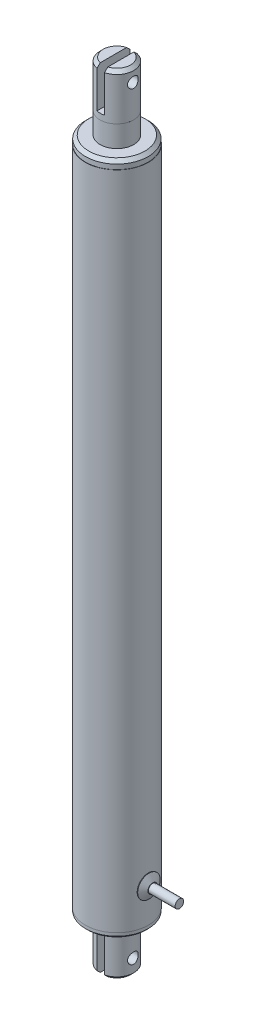
from build123d import *

# Parameters (mm, degrees)
SKETCH1_R           = 14.986
BOSS_EXTRUDE1_DEPTH = 313.944
SKETCH2_R           = 14.859
BOSS_EXTRUDE2_DEPTH = 2.54
CHAMFER1_SIZE       = 1.016
SKETCH3_R           = 8.001
BOSS_EXTRUDE3_DEPTH = 22.098
CHAMFER2_SIZE       = 1.524
SKETCH4_R           = 2.54
CUT_EXTRUDE1_DEPTH  = 21.59
SKETCH5_W           = 3.556
SKETCH5_H           = 22.881169146
CUT_EXTRUDE2_DEPTH  = 21.59
SKETCH6_R           = 5.334
BOSS_EXTRUDE4_DEPTH = 2.032
CHAMFER3_SIZE       = 1.778
CHAMFER3_SIZE2      = 3.079586336
SKETCH7_R           = 2.032
BOSS_EXTRUDE5_DEPTH = 12.7
SKETCH8_R           = 14.859
BOSS_EXTRUDE6_DEPTH = 3.81
CHAMFER4_SIZE       = 1.524
SKETCH9_R           = 8.001
BOSS_EXTRUDE7_DEPTH = 10.16
SKETCH10_R          = 8.001
BOSS_EXTRUDE8_DEPTH = 21.844
CHAMFER5_SIZE       = 1.524
SKETCH11_R          = 2.54
CUT_EXTRUDE3_DEPTH  = 21.844
SKETCH12_W          = 3.556
SKETCH12_H          = 19.05
CUT_EXTRUDE4_DEPTH  = 21.844


with BuildPart() as part:
    # Sketch1 → Boss-Extrude1 (new body)
    with BuildSketch(Plane(origin=(0, 0, 0), x_dir=(1, 0, 0), z_dir=(0, 1, 0))):
        with Locations(Location((0, 0, 0), (0, 0, 270))):  # turned: the seam where the file's is
            Circle(SKETCH1_R)
    extrude(amount=BOSS_EXTRUDE1_DEPTH)

    # Sketch2 → Boss-Extrude2 (add)
    with BuildSketch(Plane.XZ):
        with Locations(Location((0, 0, 0), (0, 0, 90))):  # turned: the seam where the file's is
            Circle(SKETCH2_R)
    extrude(amount=BOSS_EXTRUDE2_DEPTH)

    # Chamfer1
    chamfer1_edges = [part.edges().sort_by_distance(p)[0] for p in [
        (0, -2.54, -14.859),
    ]]
    chamfer(chamfer1_edges, length=CHAMFER1_SIZE)

    # Sketch3 → Boss-Extrude3 (add)
    with BuildSketch(Plane.XZ.offset(2.54)):
        with Locations(Location((0, 0, 0), (0, 0, 270))):  # turned: the seam where the file's is
            Circle(SKETCH3_R)
    extrude(amount=BOSS_EXTRUDE3_DEPTH)

    # Chamfer2
    chamfer2_edges = [part.edges().sort_by_distance(p)[0] for p in [
        (0, -24.638, 8.001),
    ]]
    chamfer(chamfer2_edges, length=CHAMFER2_SIZE)

    # Sketch4 → Cut-Extrude1 (cut)
    with BuildSketch(Plane.ZY.offset(8.001)):
        with Locations((0, -17.018)):
            Circle(SKETCH4_R)
    extrude(amount=-CUT_EXTRUDE1_DEPTH, mode=Mode.SUBTRACT)

    # Sketch5 → Cut-Extrude2 (cut)
    with BuildSketch(Plane(origin=(0, 0, -8.001), x_dir=(-1, 0, 0), z_dir=(0, 0, -1))):
        with Locations((-0.127, -17.536584573)):
            Rectangle(SKETCH5_W, SKETCH5_H)
    extrude(amount=-CUT_EXTRUDE2_DEPTH, mode=Mode.SUBTRACT)

    # Sketch8 → Boss-Extrude6 (add)
    with BuildSketch(Plane(origin=(0, 313.944, 0), x_dir=(1, 0, 0), z_dir=(0, 1, 0))):
        with Locations(Location((0, 0, 0), (0, 0, 270))):  # turned: the seam where the file's is
            Circle(SKETCH8_R)
    extrude(amount=BOSS_EXTRUDE6_DEPTH)

    # Chamfer4
    chamfer4_edges = [part.edges().sort_by_distance(p)[0] for p in [
        (0, 317.754, -14.859),
    ]]
    chamfer(chamfer4_edges, length=CHAMFER4_SIZE)

    # Sketch9 → Boss-Extrude7 (add)
    with BuildSketch(Plane(origin=(0, 317.754, 0), x_dir=(1, 0, 0), z_dir=(0, 1, 0))):
        with Locations(Location((0, 0, 0), (0, 0, 258.091508286))):  # turned: the seam where the file's is
            Circle(SKETCH9_R)
    extrude(amount=BOSS_EXTRUDE7_DEPTH)


with BuildPart() as body_2:
    # Sketch6 → Boss-Extrude4 (new body)
    with BuildSketch(Plane(origin=(14.986, 0, 0), x_dir=(0, 0, -1), z_dir=(1, 0, 0))):
        with Locations((0, 16.201300922)):
            Circle(SKETCH6_R)
    extrude(amount=BOSS_EXTRUDE4_DEPTH)

    # Chamfer3
    chamfer3_edges = [body_2.edges().sort_by_distance(p)[0] for p in [
        (17.018, 16.201300922, 5.334),
    ]]
    chamfer3_side = [body_2.faces().sort_by_distance(p)[0] for p in [
        (16.002, 16.201300922, 5.334),
    ]]
    chamfer(chamfer3_edges, length=CHAMFER3_SIZE, length2=CHAMFER3_SIZE2, reference=chamfer3_side[0])

    # Sketch7 → Boss-Extrude5 (add)
    with BuildSketch(Plane(origin=(17.018, 0, 0), x_dir=(0, 0, -1), z_dir=(1, 0, 0))):
        with Locations((0, 16.201300922)):
            Circle(SKETCH7_R)
    extrude(amount=BOSS_EXTRUDE5_DEPTH)


with BuildPart() as body_3:
    # Sketch10 → Boss-Extrude8 (new body)
    with BuildSketch(Plane(origin=(0, 327.914, 0), x_dir=(1, 0, 0), z_dir=(0, 1, 0))):
        with Locations(Location((0, 0, 0), (0, 0, 270))):  # turned: the seam where the file's is
            Circle(SKETCH10_R)
    extrude(amount=BOSS_EXTRUDE8_DEPTH)

    # Chamfer5
    chamfer5_edges = [body_3.edges().sort_by_distance(p)[0] for p in [
        (0, 349.758, -8.001),
    ]]
    chamfer(chamfer5_edges, length=CHAMFER5_SIZE)

    # Sketch11 → Cut-Extrude3 (cut)
    with BuildSketch(Plane.ZY.offset(8.001)):
        with Locations((0, 343.408)):
            Circle(SKETCH11_R)
    extrude(amount=-CUT_EXTRUDE3_DEPTH, mode=Mode.SUBTRACT)

    # Sketch12 → Cut-Extrude4 (cut)
    with BuildSketch(Plane(origin=(0, 0, -8.001), x_dir=(-1, 0, 0), z_dir=(0, 0, -1))):
        with Locations((-0.127, 340.233)):
            Rectangle(SKETCH12_W, SKETCH12_H)
    extrude(amount=-CUT_EXTRUDE4_DEPTH, mode=Mode.SUBTRACT)


solid = Compound([part.part, body_2.part, body_3.part])
